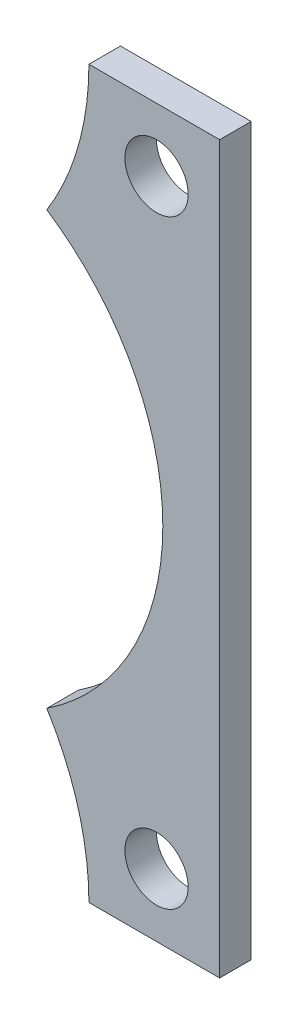
from build123d import *

# Parameters (mm, degrees)
SKETCH1_R           = 6.3627
BOSS_EXTRUDE1_DEPTH = 3.175


with BuildPart() as part:
    # Sketch1 → Boss-Extrude1 (new body, symmetric)
    with BuildSketch(Plane.XY):
        with BuildLine():
            ThreePointArc((-15.719319348, -43.426177466), (-9.406121761, -57.631125381), (-7.246114065, -73.025))
            Line((-7.246114065, -73.025), (19.05, -73.025))
            Line((19.05, -73.025), (19.05, 73.025))
            Line((19.05, 73.025), (-7.246114065, 73.025))
            ThreePointArc((-7.246114065, 73.025), (-9.406121761, 57.631125381), (-15.719319348, 43.426177466))
            ThreePointArc((-15.719319348, 43.426177466), (1.415517775, 24.650338319), (7.62, 0))
            ThreePointArc((7.62, 0), (1.415517775, -24.650338319), (-15.719319348, -43.426177466))
        make_face()
        with Locations((6.35, -60.325)):
            Circle(SKETCH1_R, mode=Mode.SUBTRACT)
        with Locations((6.35, 60.325)):
            Circle(SKETCH1_R, mode=Mode.SUBTRACT)
    extrude(amount=BOSS_EXTRUDE1_DEPTH, both=True)


solid = part.part
